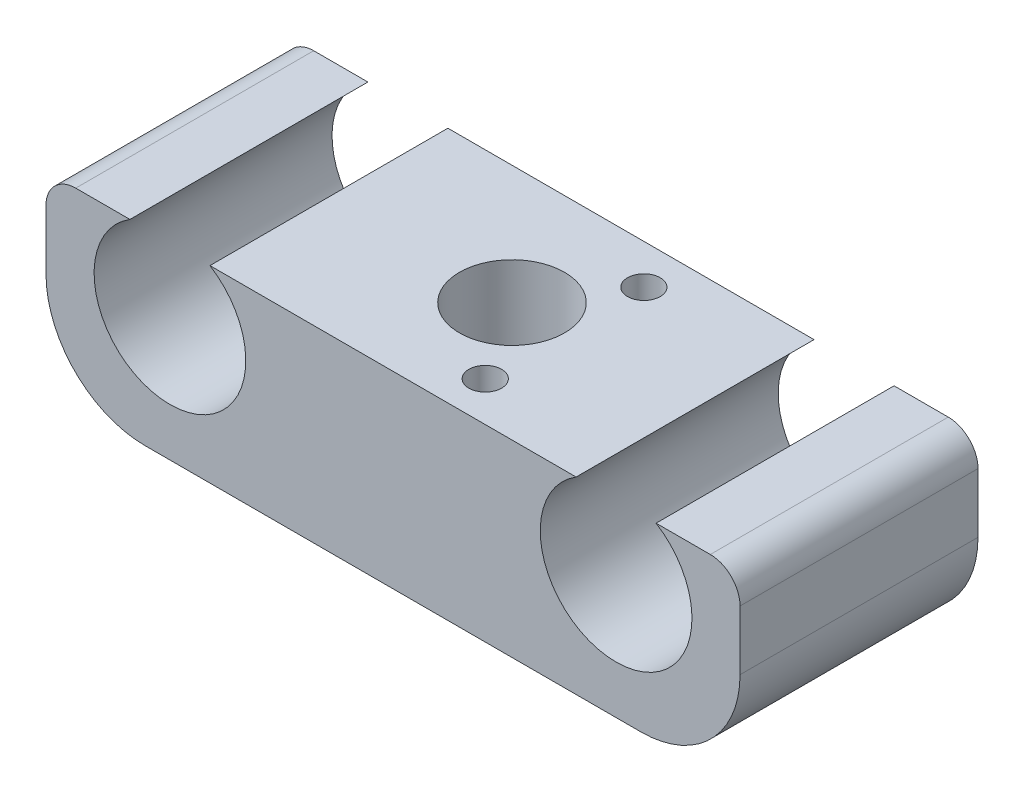
from build123d import *

# Parameters (mm, degrees)
SKETCH_1_W          = 70
SKETCH_1_H          = 19
EXTRUDE_1_DEPTH     = 24
SKETCH_2_R          = 7.65
CUT_EXTRUDE_1_DEPTH = 24
SKETCH_3_R          = 5.3
CUT_EXTRUDE_2_DEPTH = 24
FILLET_1_R          = 10
FILLET_4_R          = 3
FILLET_5_R          = 10
FILLET_6_R          = 3
SKETCH_4_R          = 1.65
CUT_EXTRUDE_3_DEPTH = 24


with BuildPart() as part:
    # 草图1 → 凸台-拉伸1 (new body)
    with BuildSketch(Plane.XY):
        with Locations((35, 9.5)):
            Rectangle(SKETCH_1_W, SKETCH_1_H)
    extrude(amount=EXTRUDE_1_DEPTH)

    # 草图2 → 切除-拉伸1 (cut)
    with BuildSketch(Plane.XY.offset(24)):
        with Locations((57.5, 12.5)):
            Circle(SKETCH_2_R)
        with Locations((12.5, 12.5)):
            Circle(SKETCH_2_R)
    extrude(amount=-CUT_EXTRUDE_1_DEPTH, mode=Mode.SUBTRACT)

    # 草图3 → 切除-拉伸2 (cut)
    with BuildSketch(Plane.XZ):
        with Locations((35, 12)):
            Circle(SKETCH_3_R)
    extrude(amount=-CUT_EXTRUDE_2_DEPTH, mode=Mode.SUBTRACT)

    # 圆角1
    fillet_1_edges = [part.edges().sort_by_distance(p)[0] for p in [
        (0, 0, 12),
    ]]
    fillet(fillet_1_edges, radius=FILLET_1_R)

    # 圆角4
    fillet_4_edges = [part.edges().sort_by_distance(p)[0] for p in [
        (0, 19, 12),
    ]]
    fillet(fillet_4_edges, radius=FILLET_4_R)

    # 圆角5
    fillet_5_edges = [part.edges().sort_by_distance(p)[0] for p in [
        (70, 0, 12),
    ]]
    fillet(fillet_5_edges, radius=FILLET_5_R)

    # 圆角6
    fillet_6_edges = [part.edges().sort_by_distance(p)[0] for p in [
        (70, 19, 12),
    ]]
    fillet(fillet_6_edges, radius=FILLET_6_R)

    # 草图4 → 切除-拉伸3 (cut)
    with BuildSketch(Plane(origin=(0, 19, 0), x_dir=(1, 0, 0), z_dir=(0, 1, 0))):
        with Locations((40.3, -20)):
            Circle(SKETCH_4_R)
        with Locations((40.3, -4)):
            Circle(SKETCH_4_R)
    extrude(amount=-CUT_EXTRUDE_3_DEPTH, mode=Mode.SUBTRACT)


solid = part.part
